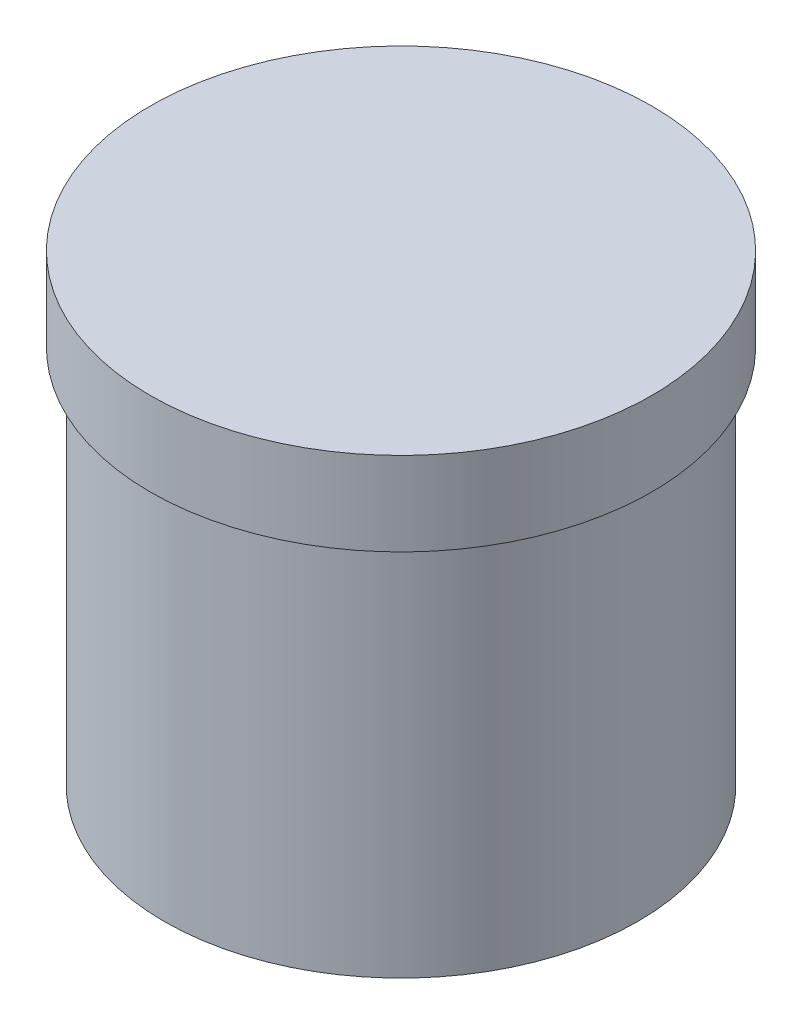
from build123d import *

# Parameters (mm, degrees)
SKETCH1_R           = 42.5
BOSS_EXTRUDE1_DEPTH = 68
SKETCH2_R           = 45
BOSS_EXTRUDE2_DEPTH = 15


with BuildPart() as part:
    # Sketch1 → Boss-Extrude1 (new body)
    with BuildSketch(Plane(origin=(0, 0, 0), x_dir=(1, 0, 0), z_dir=(0, 1, 0))):
        Circle(SKETCH1_R)
    extrude(amount=BOSS_EXTRUDE1_DEPTH)

    # Sketch2 → Boss-Extrude2 (add)
    with BuildSketch(Plane(origin=(0, 68, 0), x_dir=(1, 0, 0), z_dir=(0, 1, 0))):
        Circle(SKETCH2_R)
    extrude(amount=BOSS_EXTRUDE2_DEPTH)


solid = part.part
